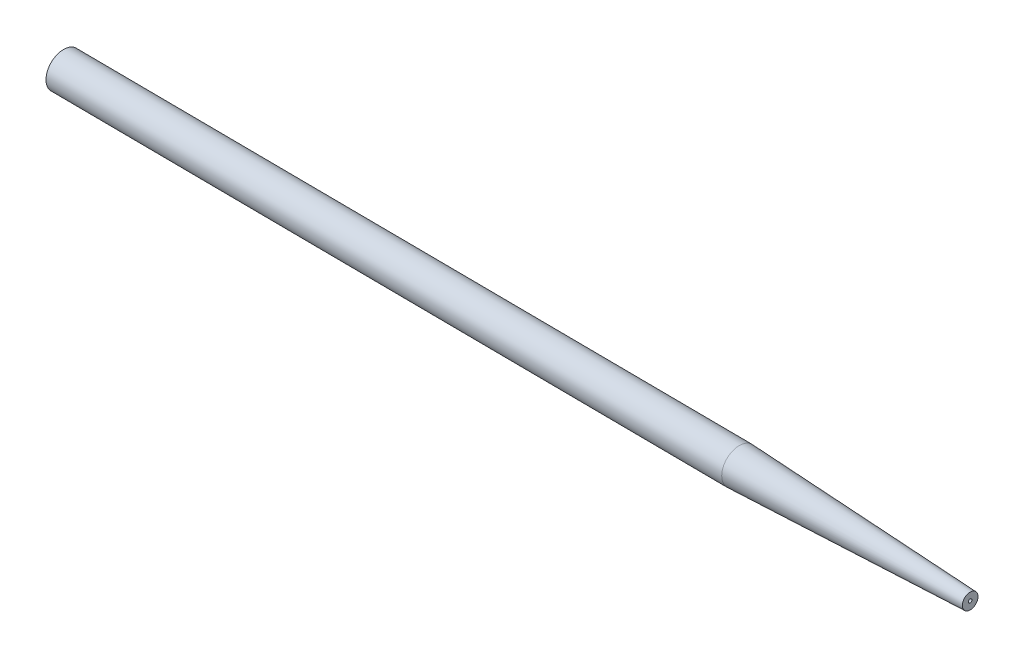
from build123d import *


with BuildPart() as part:
    # Sketch2 → Revolve1 (revolve)
    with BuildSketch(Plane(origin=(0, 0, 0), x_dir=(1, 0, 0), z_dir=(0, 1, 0))):
        with BuildLine():
            Line((11.519588192, 76.607656971), (108.313651329, 75.870184816))
            Line((108.313651329, 75.870184816), (141.380809533, 75.361662852))
            Line((141.380809533, 75.361662852), (141.380809533, 74.51501629))
            ThreePointArc((141.380809533, 74.51501629), (124.834492552, 74.310519739), (108.313651329, 73.370184816))
            Line((108.313651329, 73.370184816), (11.519588192, 74.107656971))
            Line((11.519588192, 74.107656971), (11.519588192, 76.607656971))
        make_face()
    revolve(axis=Axis((11.519588192, 0, -76.607656971), (0.999970977, 0, 0.00761876)))


solid = part.part
